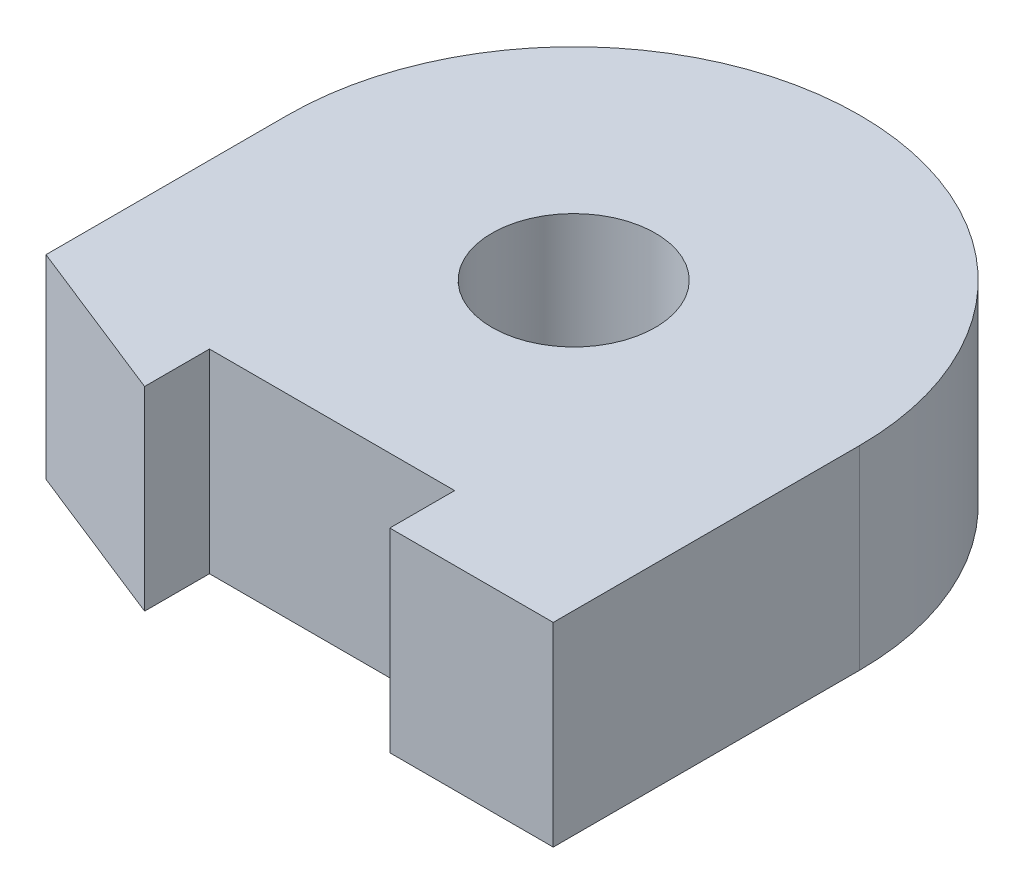
from build123d import *

# Parameters (mm, degrees)
SKETCH1_R           = 4
BOSS_EXTRUDE1_DEPTH = 9.525


with BuildPart() as part:
    # Sketch1 → Boss-Extrude1 (new body)
    with BuildSketch(Plane(origin=(0, 0, 0), x_dir=(1, 0, 0), z_dir=(0, 1, 0))):
        with BuildLine():
            Line((-6, 0), (0, 0))
            Line((0, 0), (6, 0))
            Line((6, 0), (6, -3.175))
            Line((6, -3.175), (14, -3.175))
            Line((14, -3.175), (14, 11.825))
            ThreePointArc((14, 11.825), (0, 25.825), (-14, 11.825))
            Line((-14, 11.825), (-14, 0))
            Line((-14, 0), (-6, -3.175))
            Line((-6, -3.175), (-6, 0))
        make_face()
        with Locations((0, 11.825)):
            Circle(SKETCH1_R, mode=Mode.SUBTRACT)
    extrude(amount=BOSS_EXTRUDE1_DEPTH)


solid = part.part
